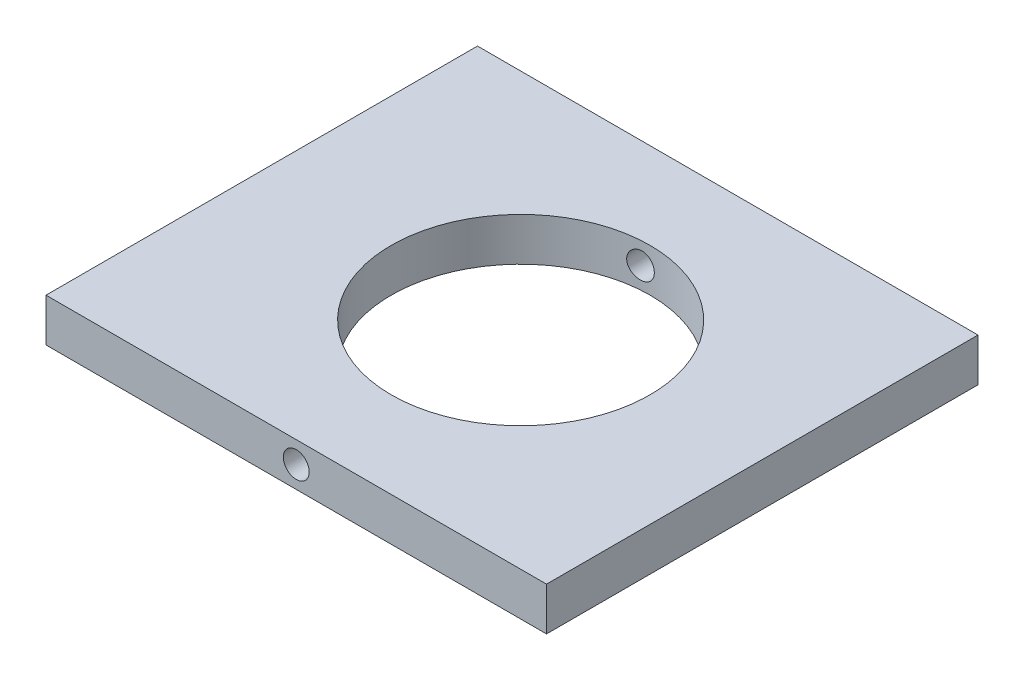
from build123d import *

# Parameters (mm, degrees)
ESQUISSE1_W             = 58
ESQUISSE1_H             = 5
BOSS_EXTRU_1_DEPTH      = 50
ESQUISSE2_R             = 15
ENL_V_MAT_EXTRU_1_DEPTH = 6
ESQUISSE5_R             = 1.5
ENL_V_MAT_EXTRU_4_DEPTH = 51


with BuildPart() as part:
    # Esquisse1 → Boss.-Extru.1 (new body)
    with BuildSketch(Plane.XY):
        with Locations((23.5, -47.5)):
            Rectangle(ESQUISSE1_W, ESQUISSE1_H)
    extrude(amount=BOSS_EXTRU_1_DEPTH)

    # Esquisse2 → Enlèv. mat.-Extru.1 (cut, through all)
    with BuildSketch(Plane(origin=(0, -45, 0), x_dir=(-1, 0, 0), z_dir=(0, 1, 0))):
        with Locations((-24.5, 25)):
            Circle(ESQUISSE2_R)
    extrude(amount=-ENL_V_MAT_EXTRU_1_DEPTH, mode=Mode.SUBTRACT)

    # Esquisse5 → Enlèv. mat.-Extru.4 (cut, through all)
    with BuildSketch(Plane.XY.offset(50)):
        with Locations((23.5, -47.5)):
            Circle(ESQUISSE5_R)
    extrude(amount=-ENL_V_MAT_EXTRU_4_DEPTH, mode=Mode.SUBTRACT)


solid = part.part
